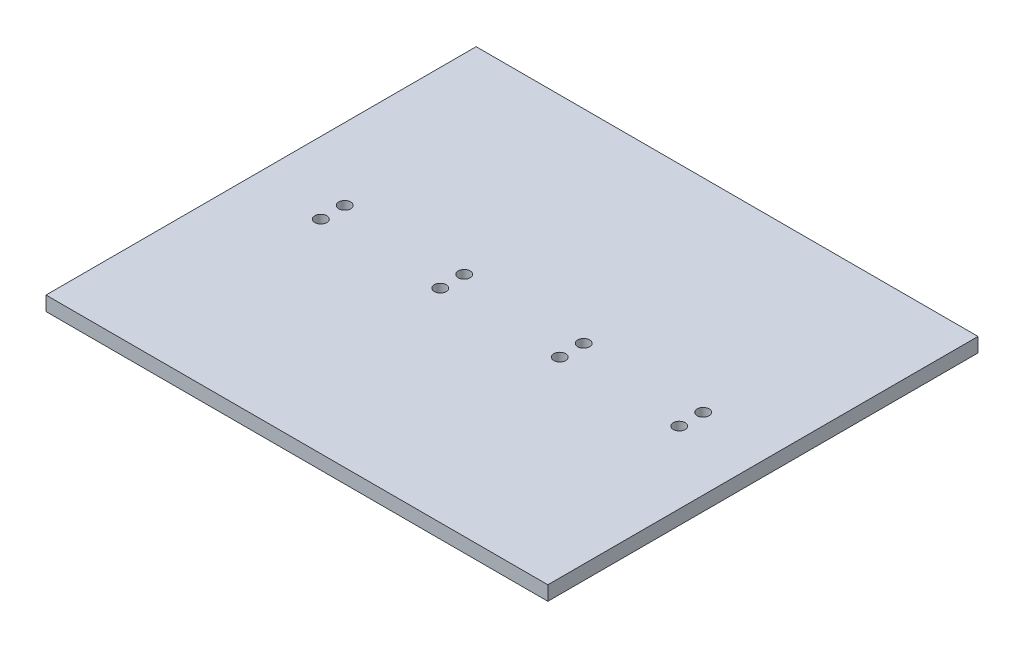
from build123d import *

# Parameters (mm, degrees)
SKETCH_1_W          = 10.5
SKETCH_1_H          = 9
EXTRUDE_1_DEPTH     = 0.3
SKETCH_2_R          = 0.125
CUT_EXTRUDE_1_DEPTH = 1.3


with BuildPart() as part:
    # Эскиз1 → Бобышка-Вытянуть1 (new body)
    with BuildSketch(Plane(origin=(0, 0, 0), x_dir=(1, 0, 0), z_dir=(0, 1, 0))):
        Rectangle(SKETCH_1_W, SKETCH_1_H)
    extrude(amount=EXTRUDE_1_DEPTH)

    # Эскиз2 → Вырез-Вытянуть1 (cut, through all)
    with BuildSketch(Plane(origin=(0, 0.3, 0), x_dir=(1, 0, 0), z_dir=(0, 1, 0))):
        with Locations((-3.75, 0.25)):
            Circle(SKETCH_2_R)
        with Locations((-1.25, 0.25)):
            Circle(SKETCH_2_R)
        with Locations((1.25, 0.25)):
            Circle(SKETCH_2_R)
        with Locations((3.75, 0.25)):
            Circle(SKETCH_2_R)
        with Locations((-1.25, -0.25)):
            Circle(SKETCH_2_R)
        with Locations((1.25, -0.25)):
            Circle(SKETCH_2_R)
        with Locations((3.75, -0.25)):
            Circle(SKETCH_2_R)
        with Locations((-3.75, -0.25)):
            Circle(SKETCH_2_R)
    extrude(amount=-CUT_EXTRUDE_1_DEPTH, mode=Mode.SUBTRACT)


solid = part.part
